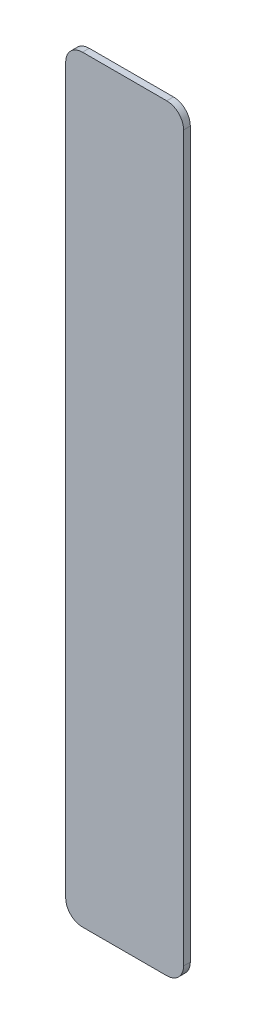
from build123d import *

# Parameters (mm, degrees)
SKETCH1_W           = 7
SKETCH1_H           = 45
BOSS_EXTRUDE1_DEPTH = 0.4
FILLET1_R           = 1


with BuildPart() as part:
    # Sketch1 → Boss-Extrude1 (new body)
    with BuildSketch(Plane.XY):
        Rectangle(SKETCH1_W, SKETCH1_H)
    extrude(amount=BOSS_EXTRUDE1_DEPTH)

    # Fillet1
    fillet1_edges = [part.edges().sort_by_distance(p)[0] for p in [
        (-3.5, 22.5, 0.2),
        (3.5, 22.5, 0.2),
        (3.5, -22.5, 0.2),
        (-3.5, -22.5, 0.2),
    ]]
    fillet(fillet1_edges, radius=FILLET1_R)


solid = part.part
